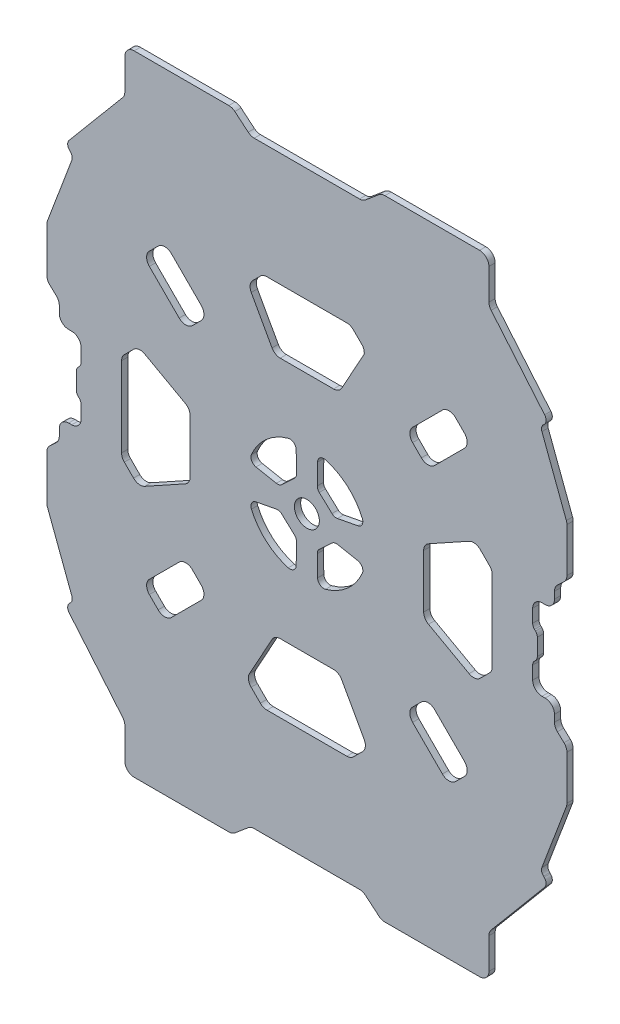
from build123d import *

# Parameters (mm, degrees)
SCHIZZO1_R                   = 4
ESTRUSIONE_ESTRUSIONE1_DEPTH = 2


with BuildPart() as part:
    # Schizzo1 → Estrusione-Estrusione1 (new body)
    with BuildSketch(Plane.XY):
        with BuildLine():
            Line((-101.81012684, -19.112083025), (-101.81012684, -13.768937275))
            ThreePointArc((-101.81012684, -13.768937275), (-101.657885905, -13.00357041), (-101.224340402, -12.354723712))
            Line((-101.224340402, -12.354723712), (-100.895913277, -12.026296588))
            ThreePointArc((-100.895913277, -12.026296588), (-100.462367775, -11.37744989), (-100.31012684, -10.612083025))
            Line((-100.31012684, -10.612083025), (-100.31012684, -6.44051015))
            ThreePointArc((-100.31012684, -6.44051015), (-101.188806496, -4.319189806), (-103.31012684, -3.44051015))
            Line((-103.31012684, -3.44051015), (-104.31012684, -3.44051015))
            ThreePointArc((-104.31012684, -3.44051015), (-106.431447183, -2.561830494), (-107.31012684, -0.44051015))
            Line((-107.31012684, -0.44051015), (-107.31012684, 1.765660902))
            ThreePointArc((-107.31012684, 1.765660902), (-107.555396796, 2.953710727), (-108.251101765, 3.947498599))
            Line((-108.251101765, 3.947498599), (-110.369151915, 5.94632664))
            ThreePointArc((-110.369151915, 5.94632664), (-111.064856883, 6.940114512), (-111.31012684, 8.128164338))
            Line((-111.31012684, 8.128164338), (-111.31012684, 22.288293647))
            ThreePointArc((-111.31012684, 22.288293647), (-111.261634841, 22.825509171), (-111.117726494, 23.345357591))
            Line((-111.117726494, 23.345357591), (-103.279134463, 44.164938463))
            ThreePointArc((-103.279134463, 44.164938463), (-103.202234994, 45.320015497), (-103.778184182, 46.324206224))
            Line((-103.778184182, 46.324206224), (-103.983488106, 46.517953874))
            ThreePointArc((-103.983488106, 46.517953874), (-104.607429033, 47.856360013), (-104.142893609, 49.258087559))
            Line((-104.142893609, 49.258087559), (-86.970761473, 69.723037724))
            ThreePointArc((-86.970761473, 69.723037724), (-86.44981694, 70.625340123), (-86.268894803, 71.651400553))
            Line((-86.268894803, 71.651400553), (-86.268894803, 81.55948985))
            ThreePointArc((-86.268894803, 81.55948985), (-85.390215146, 83.680810194), (-83.268894803, 84.55948985))
            Line((-83.268894803, 84.55948985), (-52.860805506, 84.55948985))
            ThreePointArc((-52.860805506, 84.55948985), (-51.834745076, 84.378567712), (-50.932442676, 83.857623179))
            Line((-50.932442676, 83.857623179), (-46.646578966, 80.261356521))
            ThreePointArc((-46.646578966, 80.261356521), (-45.744276567, 79.740411988), (-44.718216137, 79.55948985))
            Line((-44.718216137, 79.55948985), (-10.902037543, 79.55948985))
            ThreePointArc((-10.902037543, 79.55948985), (-9.875977113, 79.740411988), (-8.973674714, 80.261356521))
            Line((-8.973674714, 80.261356521), (-4.687811003, 83.857623179))
            ThreePointArc((-4.687811003, 83.857623179), (-3.785508604, 84.378567712), (-2.759448174, 84.55948985))
            Line((-2.759448174, 84.55948985), (27.648641123, 84.55948985))
            ThreePointArc((27.648641123, 84.55948985), (29.769961467, 83.680810194), (30.648641123, 81.55948985))
            Line((30.648641123, 81.55948985), (30.648641123, 71.651400553))
            ThreePointArc((30.648641123, 71.651400553), (30.829563261, 70.625340123), (31.350507794, 69.723037724))
            Line((31.350507794, 69.723037724), (48.522639929, 49.258087559))
            ThreePointArc((48.522639929, 49.258087559), (48.987175353, 47.856360013), (48.363234426, 46.517953874))
            Line((48.363234426, 46.517953874), (48.157930503, 46.324206224))
            ThreePointArc((48.157930503, 46.324206224), (47.581981314, 45.320015497), (47.658880783, 44.164938463))
            Line((47.658880783, 44.164938463), (55.497472814, 23.345357591))
            ThreePointArc((55.497472814, 23.345357591), (55.641381161, 22.825509171), (55.68987316, 22.288293647))
            Line((55.68987316, 22.288293647), (55.68987316, 8.128164338))
            ThreePointArc((55.68987316, 8.128164338), (55.444603204, 6.940114512), (54.748898235, 5.94632664))
            Line((54.748898235, 5.94632664), (52.630848085, 3.947498599))
            ThreePointArc((52.630848085, 3.947498599), (51.935143117, 2.953710727), (51.68987316, 1.765660902))
            Line((51.68987316, 1.765660902), (51.68987316, -0.44051015))
            ThreePointArc((51.68987316, -0.44051015), (50.811193504, -2.561830494), (48.68987316, -3.44051015))
            Line((48.68987316, -3.44051015), (47.68987316, -3.44051015))
            ThreePointArc((47.68987316, -3.44051015), (45.568552817, -4.319189806), (44.68987316, -6.44051015))
            Line((44.68987316, -6.44051015), (44.68987316, -10.612083025))
            ThreePointArc((44.68987316, -10.612083025), (44.842114095, -11.37744989), (45.275659598, -12.026296588))
            Line((45.275659598, -12.026296588), (45.604086723, -12.354723712))
            ThreePointArc((45.604086723, -12.354723712), (46.037632225, -13.00357041), (46.18987316, -13.768937275))
            Line((46.18987316, -13.768937275), (46.18987316, -19.112083025))
            ThreePointArc((46.18987316, -19.112083025), (46.037632225, -19.87744989), (45.604086723, -20.526296588))
            Line((45.604086723, -20.526296588), (45.275659598, -20.854723712))
            ThreePointArc((45.275659598, -20.854723712), (44.842114095, -21.50357041), (44.68987316, -22.268937275))
            Line((44.68987316, -22.268937275), (44.68987316, -26.44051015))
            ThreePointArc((44.68987316, -26.44051015), (45.568552817, -28.561830494), (47.68987316, -29.44051015))
            Line((47.68987316, -29.44051015), (48.68987316, -29.44051015))
            ThreePointArc((48.68987316, -29.44051015), (50.811193504, -30.319189806), (51.68987316, -32.44051015))
            Line((51.68987316, -32.44051015), (51.68987316, -34.646681201))
            ThreePointArc((51.68987316, -34.646681201), (51.935143117, -35.834731027), (52.630848085, -36.828518899))
            Line((52.630848085, -36.828518899), (54.748898235, -38.82734694))
            ThreePointArc((54.748898235, -38.82734694), (55.444603204, -39.821134812), (55.68987316, -41.009184638))
            Line((55.68987316, -41.009184638), (55.68987316, -55.169313947))
            ThreePointArc((55.68987316, -55.169313947), (55.641381161, -55.706529471), (55.497472814, -56.226377891))
            Line((55.497472814, -56.226377891), (47.658880783, -77.045958762))
            ThreePointArc((47.658880783, -77.045958762), (47.581981314, -78.201035797), (48.157930503, -79.205226524))
            Line((48.157930503, -79.205226524), (48.363234426, -79.398974174))
            ThreePointArc((48.363234426, -79.398974174), (48.987175353, -80.737380313), (48.522639929, -82.139107859))
            Line((48.522639929, -82.139107859), (31.350507794, -102.604058024))
            ThreePointArc((31.350507794, -102.604058024), (30.829563261, -103.506360423), (30.648641123, -104.532420853))
            Line((30.648641123, -104.532420853), (30.648641123, -114.44051015))
            ThreePointArc((30.648641123, -114.44051015), (29.769961467, -116.561830494), (27.648641123, -117.44051015))
            Line((27.648641123, -117.44051015), (-2.759448174, -117.44051015))
            ThreePointArc((-2.759448174, -117.44051015), (-3.785508604, -117.259588012), (-4.687811003, -116.738643479))
            Line((-4.687811003, -116.738643479), (-8.973674714, -113.142376821))
            ThreePointArc((-8.973674714, -113.142376821), (-9.875977113, -112.621432288), (-10.902037543, -112.44051015))
            Line((-10.902037543, -112.44051015), (-44.718216137, -112.44051015))
            ThreePointArc((-44.718216137, -112.44051015), (-45.744276567, -112.621432288), (-46.646578966, -113.142376821))
            Line((-46.646578966, -113.142376821), (-50.932442676, -116.738643479))
            ThreePointArc((-50.932442676, -116.738643479), (-51.834745076, -117.259588012), (-52.860805506, -117.44051015))
            Line((-52.860805506, -117.44051015), (-83.268894803, -117.44051015))
            ThreePointArc((-83.268894803, -117.44051015), (-85.390215146, -116.561830494), (-86.268894803, -114.44051015))
            Line((-86.268894803, -114.44051015), (-86.268894803, -104.532420853))
            ThreePointArc((-86.268894803, -104.532420853), (-86.44981694, -103.506360423), (-86.970761473, -102.604058024))
            Line((-86.970761473, -102.604058024), (-104.142893609, -82.139107859))
            ThreePointArc((-104.142893609, -82.139107859), (-104.607429033, -80.737380313), (-103.983488106, -79.398974174))
            Line((-103.983488106, -79.398974174), (-103.778184182, -79.205226524))
            ThreePointArc((-103.778184182, -79.205226524), (-103.202234994, -78.201035797), (-103.279134463, -77.045958762))
            Line((-103.279134463, -77.045958762), (-111.117726494, -56.226377891))
            ThreePointArc((-111.117726494, -56.226377891), (-111.261634841, -55.706529471), (-111.31012684, -55.169313947))
            Line((-111.31012684, -55.169313947), (-111.31012684, -41.009184638))
            ThreePointArc((-111.31012684, -41.009184638), (-111.064856883, -39.821134812), (-110.369151915, -38.82734694))
            Line((-110.369151915, -38.82734694), (-108.251101765, -36.828518899))
            ThreePointArc((-108.251101765, -36.828518899), (-107.555396796, -35.834731027), (-107.31012684, -34.646681201))
            Line((-107.31012684, -34.646681201), (-107.31012684, -32.44051015))
            ThreePointArc((-107.31012684, -32.44051015), (-106.431447183, -30.319189806), (-104.31012684, -29.44051015))
            Line((-104.31012684, -29.44051015), (-103.31012684, -29.44051015))
            ThreePointArc((-103.31012684, -29.44051015), (-101.188806496, -28.561830494), (-100.31012684, -26.44051015))
            Line((-100.31012684, -26.44051015), (-100.31012684, -22.268937275))
            ThreePointArc((-100.31012684, -22.268937275), (-100.462367775, -21.50357041), (-100.895913277, -20.854723712))
            Line((-100.895913277, -20.854723712), (-101.224340402, -20.526296588))
            ThreePointArc((-101.224340402, -20.526296588), (-101.657885905, -19.87744989), (-101.81012684, -19.112083025))
        make_face()
        with Locations((-27.81012684, -16.44051015)):
            Circle(SCHIZZO1_R, mode=Mode.SUBTRACT)
        with BuildLine():
            Line((-87.31012684, -29.259558911), (-87.31012684, -3.621461389))
            ThreePointArc((-87.31012684, -3.621461389), (-87.081765437, -2.473411092), (-86.431447183, -1.500141046))
            Line((-86.431447183, -1.500141046), (-83.469273399, 1.462032738))
            ThreePointArc((-83.469273399, 1.462032738), (-81.766430495, 2.311381786), (-79.895217018, 1.96550915))
            Line((-79.895217018, 1.96550915), (-66.857390802, -5.250485752))
            ThreePointArc((-66.857390802, -5.250485752), (-65.725730574, -6.351833806), (-65.31012684, -7.875282507))
            Line((-65.31012684, -7.875282507), (-65.31012684, -25.005737793))
            ThreePointArc((-65.31012684, -25.005737793), (-65.725730574, -26.529186494), (-66.857390802, -27.630534548))
            Line((-66.857390802, -27.630534548), (-79.895217018, -34.84652945))
            ThreePointArc((-79.895217018, -34.84652945), (-81.766430495, -35.192402086), (-83.469273399, -34.343053038))
            Line((-83.469273399, -34.343053038), (-86.431447183, -31.380879254))
            ThreePointArc((-86.431447183, -31.380879254), (-87.081765437, -30.407609208), (-87.31012684, -29.259558911))
        make_face(mode=Mode.SUBTRACT)
        with BuildLine():
            Line((-78.392600126, 31.307279648), (-75.557916638, 34.141963136))
            ThreePointArc((-75.557916638, 34.141963136), (-73.436596294, 35.020642793), (-71.315275951, 34.141963136))
            Line((-71.315275951, 34.141963136), (-61.748124155, 24.574811341))
            ThreePointArc((-61.748124155, 24.574811341), (-60.869444499, 22.453490997), (-61.748124155, 20.332170653))
            Line((-61.748124155, 20.332170653), (-64.582807643, 17.497487165))
            ThreePointArc((-64.582807643, 17.497487165), (-66.704127987, 16.618807509), (-68.82544833, 17.497487165))
            Line((-68.82544833, 17.497487165), (-78.392600126, 27.064638961))
            ThreePointArc((-78.392600126, 27.064638961), (-79.271279782, 29.185959305), (-78.392600126, 31.307279648))
        make_face(mode=Mode.SUBTRACT)
        with BuildLine():
            Line((-44.153489845, -11.590631732), (-37.606858493, -12.84520209))
            ThreePointArc((-37.606858493, -12.84520209), (-36.675184885, -12.802323639), (-35.864258182, -12.341615318))
            Line((-35.864258182, -12.341615318), (-31.776810778, -8.518589702))
            ThreePointArc((-31.776810778, -8.518589702), (-31.302356478, -7.840270347), (-31.14321353, -7.027929563))
            Line((-31.14321353, -7.027929563), (-31.243595517, -0.334264162))
            ThreePointArc((-31.243595517, -0.334264162), (-32.049574747, 1.240380408), (-33.789433074, 1.559756434))
            ThreePointArc((-33.789433074, 1.559756434), (-40.877919969, -2.302556887), (-45.615401853, -8.83863951))
            ThreePointArc((-45.615401853, -8.83863951), (-45.543321165, -10.564643055), (-44.153489845, -11.590631732))
        make_face(mode=Mode.SUBTRACT)
        with BuildLine():
            Line((-36.375354483, 22.55948985), (-19.244899196, 22.55948985))
            ThreePointArc((-19.244899196, 22.55948985), (-17.721450496, 22.975093585), (-16.620102442, 24.106753812))
            Line((-16.620102442, 24.106753812), (-9.40410754, 37.144580028))
            ThreePointArc((-9.40410754, 37.144580028), (-9.465166673, 38.227895492), (-9.907583951, 39.218636409))
            Line((-9.907583951, 39.218636409), (-12.869757736, 42.180810194))
            ThreePointArc((-12.869757736, 42.180810194), (-13.843027782, 42.831128448), (-14.991078079, 43.05948985))
            Line((-14.991078079, 43.05948985), (-40.6291756, 43.05948985))
            ThreePointArc((-40.6291756, 43.05948985), (-41.777225898, 42.831128448), (-42.750495944, 42.180810194))
            Line((-42.750495944, 42.180810194), (-45.17825243, 39.753053707))
            ThreePointArc((-45.17825243, 39.753053707), (-46.027601478, 38.050210803), (-45.681728842, 36.178997326))
            Line((-45.681728842, 36.178997326), (-39.000151238, 24.106753812))
            ThreePointArc((-39.000151238, 24.106753812), (-37.898803184, 22.975093585), (-36.375354483, 22.55948985))
        make_face(mode=Mode.SUBTRACT)
        with BuildLine():
            Line((-24.477040149, -7.027929563), (-24.376658162, -0.334264162))
            ThreePointArc((-24.376658162, -0.334264162), (-23.570678932, 1.240380408), (-21.830820606, 1.559756434))
            ThreePointArc((-21.830820606, 1.559756434), (-14.74233371, -2.302556887), (-10.004851827, -8.83863951))
            ThreePointArc((-10.004851827, -8.83863951), (-10.076932514, -10.564643055), (-11.466763835, -11.590631732))
            Line((-11.466763835, -11.590631732), (-18.013395186, -12.84520209))
            ThreePointArc((-18.013395186, -12.84520209), (-18.945068795, -12.802323639), (-19.755995497, -12.341615318))
            Line((-19.755995497, -12.341615318), (-23.843442902, -8.518589702))
            ThreePointArc((-23.843442902, -8.518589702), (-24.317897201, -7.840270347), (-24.477040149, -7.027929563))
        make_face(mode=Mode.SUBTRACT)
        with BuildLine():
            Line((13.205194651, 17.497487165), (22.772346446, 27.064638961))
            ThreePointArc((22.772346446, 27.064638961), (23.651026103, 29.185959305), (22.772346446, 31.307279648))
            Line((22.772346446, 31.307279648), (19.937662958, 34.141963136))
            ThreePointArc((19.937662958, 34.141963136), (17.816342615, 35.020642793), (15.695022271, 34.141963136))
            Line((15.695022271, 34.141963136), (6.127870475, 24.574811341))
            ThreePointArc((6.127870475, 24.574811341), (5.249190819, 22.453490997), (6.127870475, 20.332170653))
            Line((6.127870475, 20.332170653), (8.962553964, 17.497487165))
            ThreePointArc((8.962553964, 17.497487165), (11.083874307, 16.618807509), (13.205194651, 17.497487165))
        make_face(mode=Mode.SUBTRACT)
        with BuildLine():
            Line((9.68987316, -7.875282507), (9.68987316, -25.005737793))
            ThreePointArc((9.68987316, -25.005737793), (10.105476895, -26.529186494), (11.237137122, -27.630534548))
            Line((11.237137122, -27.630534548), (24.274963338, -34.84652945))
            ThreePointArc((24.274963338, -34.84652945), (26.146176816, -35.192402086), (27.84901972, -34.343053038))
            Line((27.84901972, -34.343053038), (30.811193504, -31.380879254))
            ThreePointArc((30.811193504, -31.380879254), (31.461511758, -30.407609208), (31.68987316, -29.259558911))
            Line((31.68987316, -29.259558911), (31.68987316, -3.621461389))
            ThreePointArc((31.68987316, -3.621461389), (31.461511758, -2.473411092), (30.811193504, -1.500141046))
            Line((30.811193504, -1.500141046), (27.84901972, 1.462032738))
            ThreePointArc((27.84901972, 1.462032738), (26.146176816, 2.311381786), (24.274963338, 1.96550915))
            Line((24.274963338, 1.96550915), (11.237137122, -5.250485752))
            ThreePointArc((11.237137122, -5.250485752), (10.105476895, -6.351833806), (9.68987316, -7.875282507))
        make_face(mode=Mode.SUBTRACT)
        with BuildLine():
            Line((22.772346446, -64.188299948), (19.937662958, -67.022983436))
            ThreePointArc((19.937662958, -67.022983436), (17.816342615, -67.901663093), (15.695022271, -67.022983436))
            Line((15.695022271, -67.022983436), (6.127870475, -57.455831641))
            ThreePointArc((6.127870475, -57.455831641), (5.249190819, -55.334511297), (6.127870475, -53.213190953))
            Line((6.127870475, -53.213190953), (8.962553964, -50.378507465))
            ThreePointArc((8.962553964, -50.378507465), (11.083874307, -49.499827809), (13.205194651, -50.378507465))
            Line((13.205194651, -50.378507465), (22.772346446, -59.945659261))
            ThreePointArc((22.772346446, -59.945659261), (23.651026103, -62.066979604), (22.772346446, -64.188299948))
        make_face(mode=Mode.SUBTRACT)
        with BuildLine():
            Line((-11.466763835, -21.290388567), (-18.013395186, -20.03581821))
            ThreePointArc((-18.013395186, -20.03581821), (-18.945068795, -20.078696661), (-19.755995497, -20.539404982))
            Line((-19.755995497, -20.539404982), (-23.843442902, -24.362430598))
            ThreePointArc((-23.843442902, -24.362430598), (-24.317897201, -25.040749952), (-24.477040149, -25.853090737))
            Line((-24.477040149, -25.853090737), (-24.376658162, -32.546756138))
            ThreePointArc((-24.376658162, -32.546756138), (-23.570678932, -34.121400708), (-21.830820606, -34.440776734))
            ThreePointArc((-21.830820606, -34.440776734), (-14.74233371, -30.578463413), (-10.004851827, -24.04238079))
            ThreePointArc((-10.004851827, -24.04238079), (-10.076932514, -22.316377244), (-11.466763835, -21.290388567))
        make_face(mode=Mode.SUBTRACT)
        with BuildLine():
            Line((-9.40410754, -70.025600328), (-16.620102442, -56.987774112))
            ThreePointArc((-16.620102442, -56.987774112), (-17.721450496, -55.856113885), (-19.244899196, -55.44051015))
            Line((-19.244899196, -55.44051015), (-36.375354483, -55.44051015))
            ThreePointArc((-36.375354483, -55.44051015), (-37.898803184, -55.856113885), (-39.000151238, -56.987774112))
            Line((-39.000151238, -56.987774112), (-46.216146139, -70.025600328))
            ThreePointArc((-46.216146139, -70.025600328), (-46.562018776, -71.896813806), (-45.712669728, -73.599656709))
            Line((-45.712669728, -73.599656709), (-42.750495944, -76.561830494))
            ThreePointArc((-42.750495944, -76.561830494), (-41.777225898, -77.212148748), (-40.6291756, -77.44051015))
            Line((-40.6291756, -77.44051015), (-14.991078079, -77.44051015))
            ThreePointArc((-14.991078079, -77.44051015), (-13.843027782, -77.212148748), (-12.869757736, -76.561830494))
            Line((-12.869757736, -76.561830494), (-9.907583951, -73.599656709))
            ThreePointArc((-9.907583951, -73.599656709), (-9.058234904, -71.896813806), (-9.40410754, -70.025600328))
        make_face(mode=Mode.SUBTRACT)
        with BuildLine():
            Line((-31.14321353, -25.853090737), (-31.243595517, -32.546756138))
            ThreePointArc((-31.243595517, -32.546756138), (-32.049574747, -34.121400708), (-33.789433074, -34.440776734))
            ThreePointArc((-33.789433074, -34.440776734), (-40.877919969, -30.578463413), (-45.615401853, -24.04238079))
            ThreePointArc((-45.615401853, -24.04238079), (-45.543321165, -22.316377244), (-44.153489845, -21.290388567))
            Line((-44.153489845, -21.290388567), (-37.606858493, -20.03581821))
            ThreePointArc((-37.606858493, -20.03581821), (-36.675184885, -20.078696661), (-35.864258182, -20.539404982))
            Line((-35.864258182, -20.539404982), (-31.776810778, -24.362430598))
            ThreePointArc((-31.776810778, -24.362430598), (-31.302356478, -25.040749952), (-31.14321353, -25.853090737))
        make_face(mode=Mode.SUBTRACT)
        with BuildLine():
            Line((-68.82544833, -50.378507465), (-78.392600126, -59.945659261))
            ThreePointArc((-78.392600126, -59.945659261), (-79.271279782, -62.066979604), (-78.392600126, -64.188299948))
            Line((-78.392600126, -64.188299948), (-75.557916638, -67.022983436))
            ThreePointArc((-75.557916638, -67.022983436), (-73.436596294, -67.901663093), (-71.315275951, -67.022983436))
            Line((-71.315275951, -67.022983436), (-61.748124155, -57.455831641))
            ThreePointArc((-61.748124155, -57.455831641), (-60.869444499, -55.334511297), (-61.748124155, -53.213190953))
            Line((-61.748124155, -53.213190953), (-64.582807643, -50.378507465))
            ThreePointArc((-64.582807643, -50.378507465), (-66.704127987, -49.499827809), (-68.82544833, -50.378507465))
        make_face(mode=Mode.SUBTRACT)
    extrude(amount=ESTRUSIONE_ESTRUSIONE1_DEPTH)


solid = part.part
